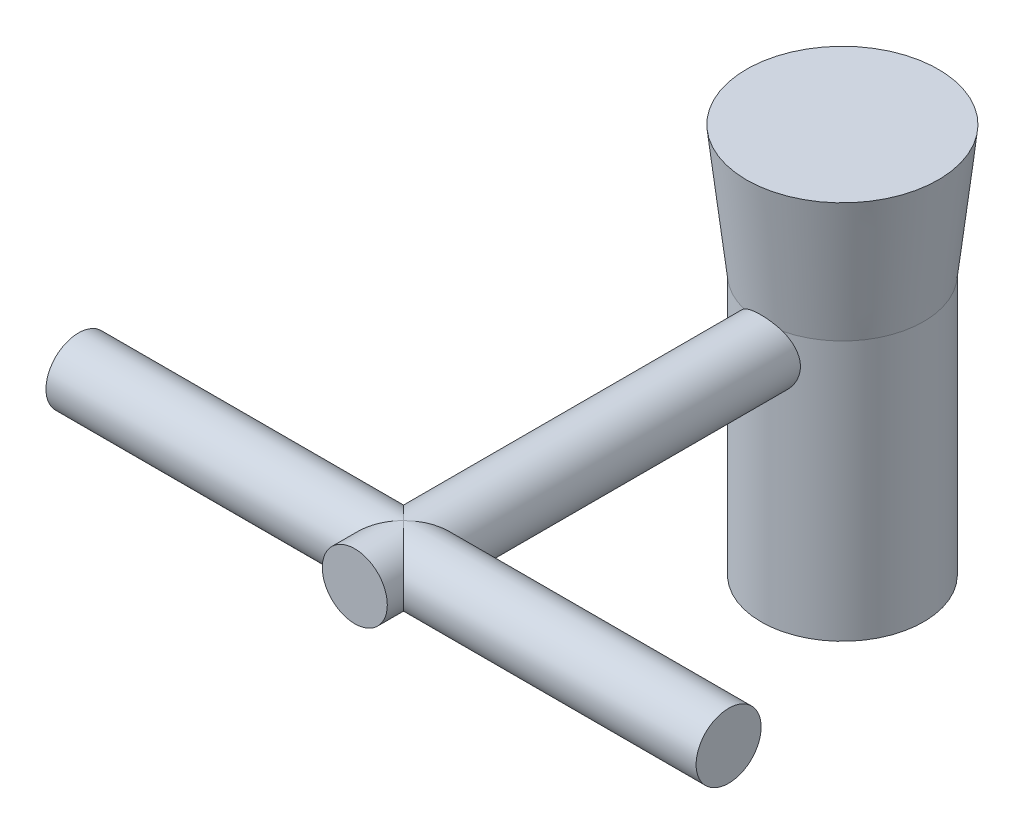
from build123d import *

# Parameters (mm, degrees)
SKETCH1_R           = 12.5
BOSS_EXTRUDE1_DEPTH = 40
SKETCH3_R           = 14.75
SKETCH2_R           = 12.5
SKETCH4_R           = 5
BOSS_EXTRUDE2_DEPTH = 75
SKETCH5_R           = 5
BOSS_EXTRUDE3_DEPTH = 50


with BuildPart() as part:
    # Sketch1 → Boss-Extrude1 (new body)
    with BuildSketch(Plane(origin=(0, 0, 0), x_dir=(1, 0, 0), z_dir=(0, 1, 0))):
        Circle(SKETCH1_R)
    extrude(amount=BOSS_EXTRUDE1_DEPTH)

    # Sketch3 → Loft1 section 0
    with BuildSketch(Plane(origin=(0, 60, 0), x_dir=(1, 0, 0), z_dir=(0, 1, 0))):
        Circle(SKETCH3_R)
    # Sketch2 → Loft1 section 1
    with BuildSketch(Plane(origin=(0, 40, 0), x_dir=(1, 0, 0), z_dir=(0, 1, 0))):
        Circle(SKETCH2_R)
    loft()

    # Sketch4 → Boss-Extrude2 (add)
    with BuildSketch(Plane.XY):
        with Locations((0, 36)):
            Circle(SKETCH4_R)
    extrude(amount=BOSS_EXTRUDE2_DEPTH)

    # Sketch5 → Boss-Extrude3 (add, symmetric)
    with BuildSketch(Plane(origin=(0, 0, 0), x_dir=(0, 0, -1), z_dir=(1, 0, 0))):
        with Locations((-67.5, 36)):
            Circle(SKETCH5_R)
    extrude(amount=BOSS_EXTRUDE3_DEPTH, both=True)


solid = part.part
